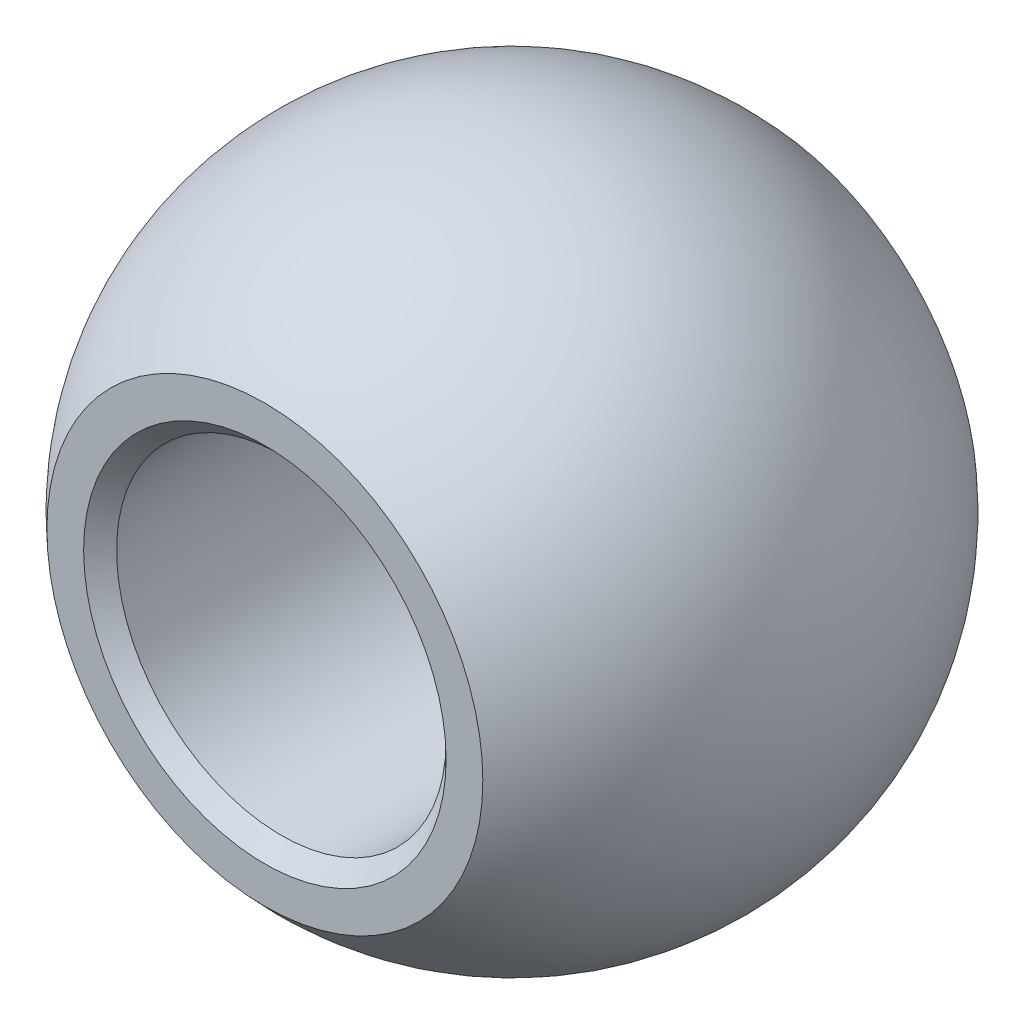
from build123d import *

# Parameters (mm, degrees)
SKETCH10_R              = 3.175
CUT_EXTRUDE4_DEPTH      = 7.35
CUT_EXTRUDE4_DEPTH_BACK = 7.35
CUT_EXTRUDE7_START      = -4.7625
SKETCH22_W              = 19.05
SKETCH22_H              = 23.8125
CUT_EXTRUDE7_DEPTH      = 2.5875
CUT_EXTRUDE8_START      = 4.7625
SKETCH23_W              = 19.05
SKETCH23_H              = 23.8125
CUT_EXTRUDE8_DEPTH      = 2.5875
CHAMFER2_SIZE           = 0.3175


with BuildPart() as part:
    # Sketch7 → Revolve3 (revolve)
    with BuildSketch(Plane.XY):
        with BuildLine():
            Line((0, 20.6375), (0, 7.9375))
            ThreePointArc((0, 7.9375), (6.35, 14.2875), (0, 20.6375))
        make_face()
    revolve(axis=Axis((0, 0, 0), (0, 1, 0)))

    # Sketch10 → Cut-Extrude4 (cut, two sides)
    with BuildSketch(Plane.XY) as cut_extrude4_sk:
        with Locations((0, 14.2875)):
            Circle(SKETCH10_R)
    extrude(amount=CUT_EXTRUDE4_DEPTH, mode=Mode.SUBTRACT)
    extrude(cut_extrude4_sk.sketch, amount=-CUT_EXTRUDE4_DEPTH_BACK, mode=Mode.SUBTRACT)

    # Sketch22 → Cut-Extrude7 (cut, through all)
    with BuildSketch(Plane.XY.offset(CUT_EXTRUDE7_START)):
        with Locations((0, 11.90625)):
            Rectangle(SKETCH22_W, SKETCH22_H)
    extrude(amount=-CUT_EXTRUDE7_DEPTH, mode=Mode.SUBTRACT)

    # Sketch23 → Cut-Extrude8 (cut, through all)
    with BuildSketch(Plane.XY.offset(CUT_EXTRUDE8_START)):
        with Locations((0, 11.90625)):
            Rectangle(SKETCH23_W, SKETCH23_H)
    extrude(amount=CUT_EXTRUDE8_DEPTH, mode=Mode.SUBTRACT)

    # Chamfer2
    chamfer2_edges = [part.edges().sort_by_distance(p)[0] for p in [
        (-3.175, 14.2875, -4.7625),
        (-3.175, 14.2875, 4.7625),
    ]]
    chamfer(chamfer2_edges, length=CHAMFER2_SIZE)


solid = part.part
